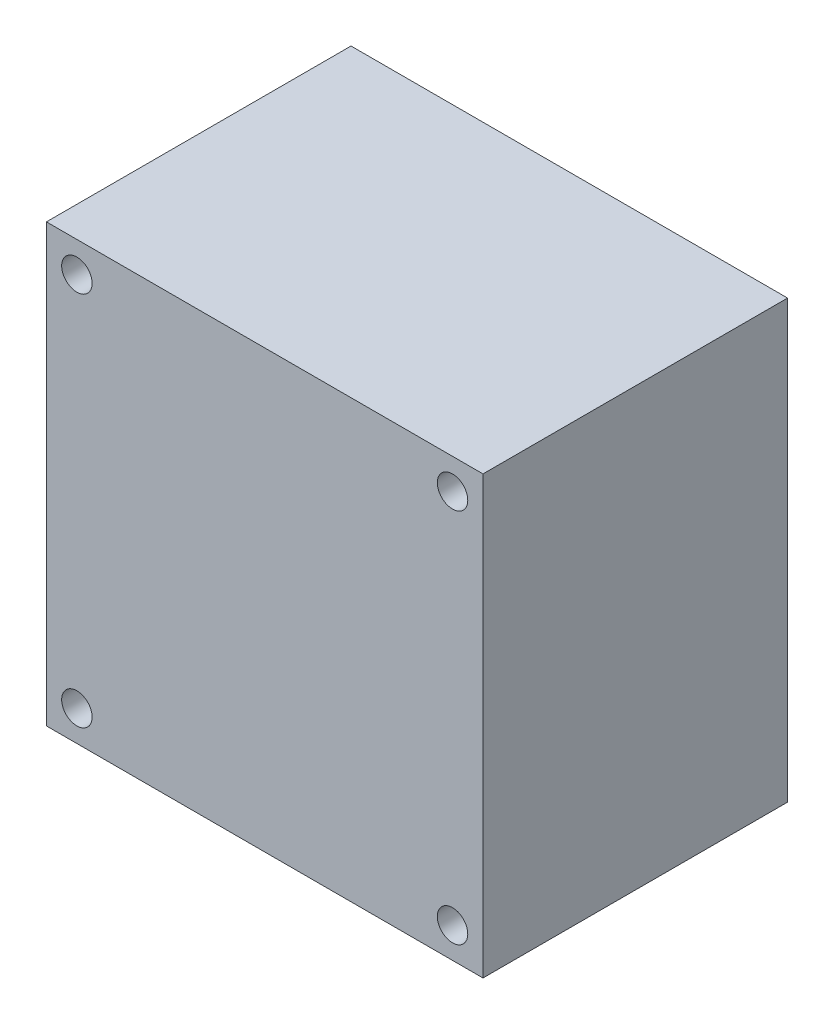
from build123d import *

# Parameters (mm, degrees)
ESQUISSE1_W             = 43
ESQUISSE1_H             = 43
BOSS_EXTRU_1_DEPTH      = 30
ESQUISSE2_R             = 1.5
ENL_V_MAT_EXTRU_1_DEPTH = 31


with BuildPart() as part:
    # Esquisse1 → Boss.-Extru.1 (new body)
    with BuildSketch(Plane.XY):
        with Locations((21.5, 21.5)):
            Rectangle(ESQUISSE1_W, ESQUISSE1_H)
    extrude(amount=BOSS_EXTRU_1_DEPTH)

    # Esquisse2 → Enlèv. mat.-Extru.1 (cut, through all)
    with BuildSketch(Plane.XY.offset(30)):
        with Locations((3, 40)):
            Circle(ESQUISSE2_R)
        with Locations((40, 40)):
            Circle(ESQUISSE2_R)
        with Locations((40, 3)):
            Circle(ESQUISSE2_R)
        with Locations((3, 3)):
            Circle(ESQUISSE2_R)
    extrude(amount=-ENL_V_MAT_EXTRU_1_DEPTH, mode=Mode.SUBTRACT)


solid = part.part
